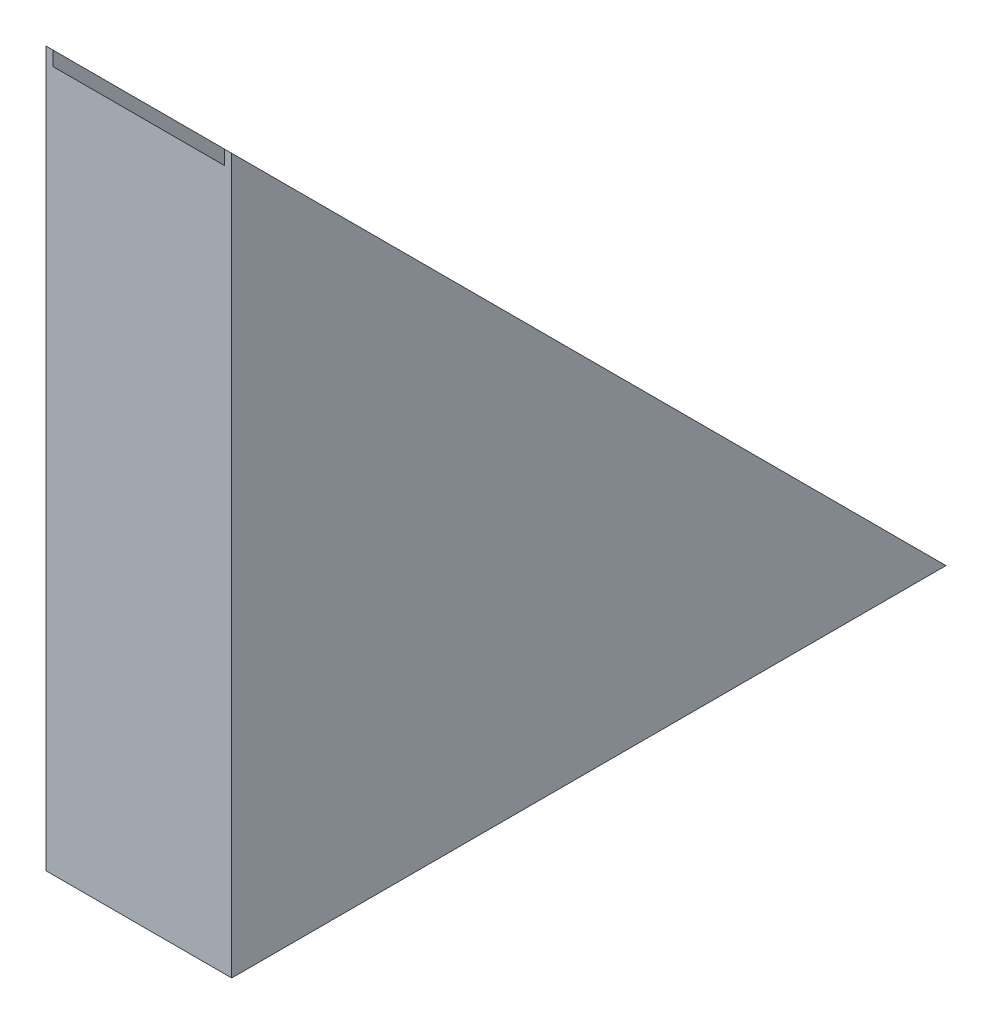
from build123d import *

# Parameters (mm, degrees)
BOSS_EXTRUDE1_DEPTH = 650
SKETCH5_W           = 600
SKETCH5_H           = 3535.533905932
CUT_EXTRUDE1_DEPTH  = 35.36


with BuildPart() as part:
    # Sketch3 → Boss-Extrude1 (new body)
    with BuildSketch(Plane(origin=(0, 0, 0), x_dir=(0, 0, -1), z_dir=(1, 0, 0))):
        Polygon((0, 0), (2500, 0), (0, 2500), align=None)
    extrude(amount=BOSS_EXTRUDE1_DEPTH)

    # Sketch5 → Cut-Extrude1 (cut)
    with BuildSketch(Plane(origin=(0, 1250, -1250), x_dir=(1, 0, 0), z_dir=(0, 0.707106781, -0.707106781))):
        with Locations((325, 0)):
            Rectangle(SKETCH5_W, SKETCH5_H)
    extrude(amount=-CUT_EXTRUDE1_DEPTH, mode=Mode.SUBTRACT)


solid = part.part
